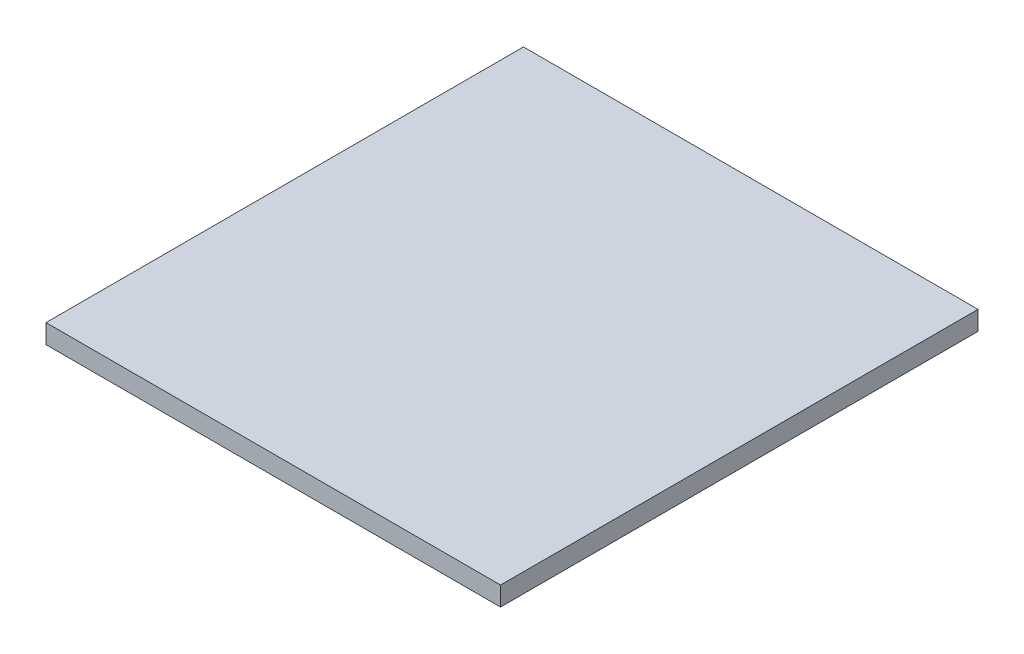
from build123d import *

# Parameters (mm, degrees)
SKETCH_2_W      = 238
SKETCH_2_H      = 250
EXTRUDE_1_DEPTH = 10


with BuildPart() as part:
    # Эскиз2 → Бобышка-Вытянуть1 (new body)
    with BuildSketch(Plane(origin=(0, 0, 0), x_dir=(1, 0, 0), z_dir=(0, 1, 0))):
        with Locations((119, 125)):
            Rectangle(SKETCH_2_W, SKETCH_2_H)
    extrude(amount=EXTRUDE_1_DEPTH)


solid = part.part
